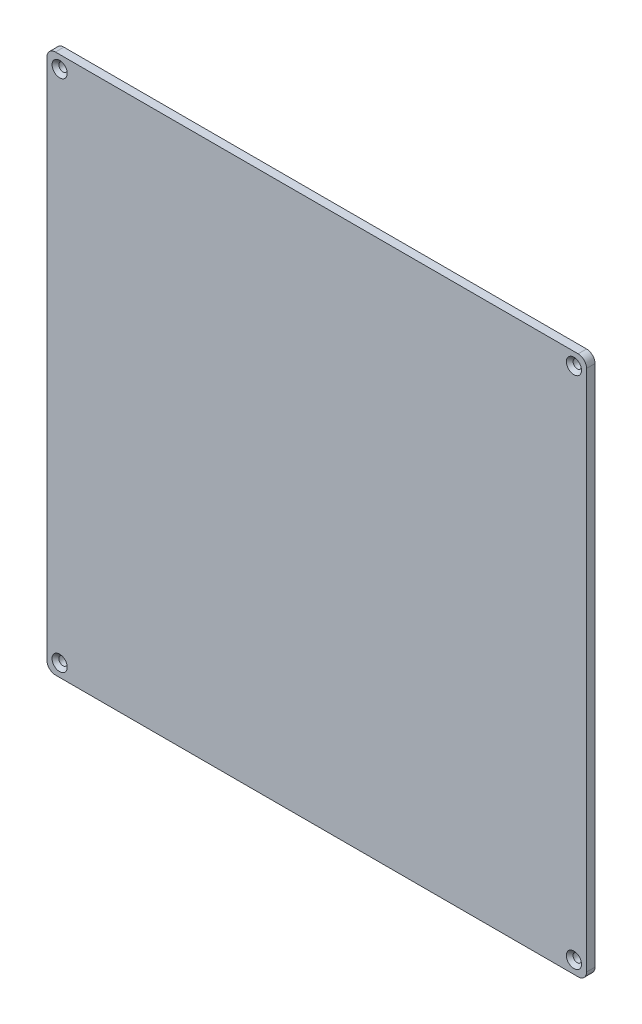
from build123d import *

# Parameters (mm, degrees)
ESQUISSE1_W        = 320
ESQUISSE1_H        = 320
ESQUISSE1_R        = 2.5
BOSS_EXTRU_1_DEPTH = 5
CONG_1_R           = 5
CHANFREIN1_SIZE    = 2


with BuildPart() as part:
    # Esquisse1 → Boss.-Extru.1 (new body)
    with BuildSketch(Plane.XY):
        with Locations((160, 160)):
            Rectangle(ESQUISSE1_W, ESQUISSE1_H)
        with Locations((7.5, 312.5)):
            Circle(ESQUISSE1_R, mode=Mode.SUBTRACT)
        with Locations((312.5, 312.5)):
            Circle(ESQUISSE1_R, mode=Mode.SUBTRACT)
        with Locations((7.5, 7.5)):
            Circle(ESQUISSE1_R, mode=Mode.SUBTRACT)
        with Locations((312.5, 7.5)):
            Circle(ESQUISSE1_R, mode=Mode.SUBTRACT)
    extrude(amount=BOSS_EXTRU_1_DEPTH)

    # Congé1
    cong_1_edges = [part.edges().sort_by_distance(p)[0] for p in [
        (0, 0, 2.5),
        (0, 320, 2.5),
        (320, 320, 2.5),
        (320, 0, 2.5),
    ]]
    fillet(cong_1_edges, radius=CONG_1_R)

    # Chanfrein1
    chanfrein1_edges = [part.edges().sort_by_distance(p)[0] for p in [
        (310, 312.5, 5),
        (5, 312.5, 5),
        (5, 7.5, 5),
        (310, 7.5, 5),
    ]]
    chamfer(chanfrein1_edges, length=CHANFREIN1_SIZE)


solid = part.part
